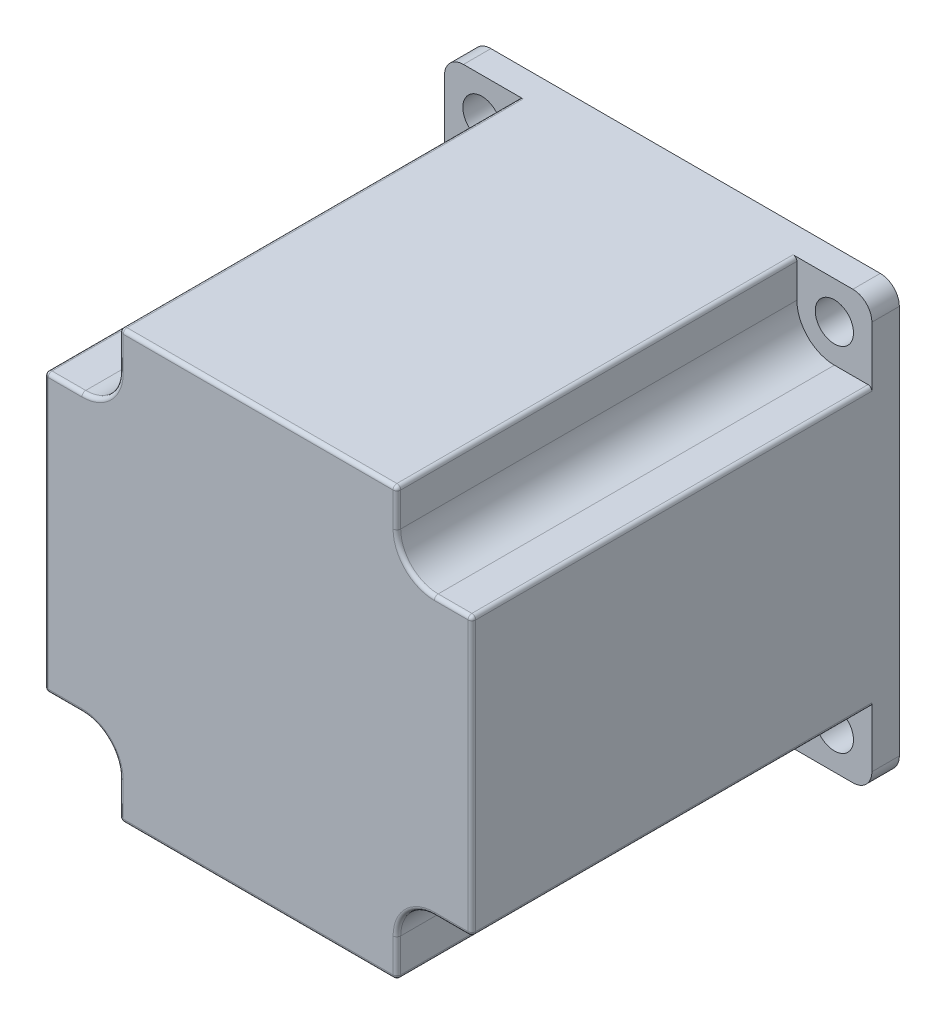
from build123d import *

# Parameters (mm, degrees)
SKETCH1_W           = 57
SKETCH1_H           = 57
BOSS_EXTRUDE1_DEPTH = 57
SKETCH2_R           = 2.55
CUT_EXTRUDE1_DEPTH  = 58
CUT_EXTRUDE2_DEPTH  = 53.34
SKETCH4_R           = 19.05
BOSS_EXTRUDE2_DEPTH = 1.6
SKETCH5_R           = 3.175
BOSS_EXTRUDE3_DEPTH = 19.4
CUT_EXTRUDE3_DEPTH  = 15
CHAMFER1_SIZE2      = 0.439940905
CHAMFER1_SIZE       = 0.254
FILLET1_R           = 2.54
FILLET2_R           = 0.508


with BuildPart() as part:
    # Sketch1 → Boss-Extrude1 (new body)
    with BuildSketch(Plane.XY):
        Rectangle(SKETCH1_W, SKETCH1_H)
    extrude(amount=BOSS_EXTRUDE1_DEPTH)

    # Sketch2 → Cut-Extrude1 (cut, through all)
    with BuildSketch(Plane.XY.offset(57)):
        with Locations((-23.5, 23.5)):
            Circle(SKETCH2_R)
        with Locations((23.5, 23.5)):
            Circle(SKETCH2_R)
        with Locations((23.5, -23.5)):
            Circle(SKETCH2_R)
        with Locations((-23.5, -23.5)):
            Circle(SKETCH2_R)
    extrude(amount=-CUT_EXTRUDE1_DEPTH, mode=Mode.SUBTRACT)

    # Sketch3 → Cut-Extrude2 (cut)
    with BuildSketch(Plane.XY.offset(57)):
        with BuildLine():
            Line((-18.5, 23.5), (-18.5, 28.5))
            Line((-18.5, 28.5), (-28.5, 28.5))
            Line((-28.5, 28.5), (-28.5, 18.5))
            Line((-28.5, 18.5), (-23.5, 18.5))
            ThreePointArc((-23.5, 18.5), (-19.964466094, 19.964466094), (-18.5, 23.5))
        make_face()
        with BuildLine():
            Line((28.5, 28.5), (28.5, 18.5))
            Line((28.5, 18.5), (23.5, 18.5))
            ThreePointArc((23.5, 18.5), (19.964466094, 19.964466094), (18.5, 23.5))
            Line((18.5, 23.5), (18.5, 28.5))
            Line((18.5, 28.5), (28.5, 28.5))
        make_face()
        with BuildLine():
            Line((-28.5, -28.5), (-28.5, -18.5))
            Line((-28.5, -18.5), (-23.5, -18.5))
            ThreePointArc((-23.5, -18.5), (-19.964466094, -19.964466094), (-18.5, -23.5))
            Line((-18.5, -23.5), (-18.5, -28.5))
            Line((-18.5, -28.5), (-28.5, -28.5))
        make_face()
        with BuildLine():
            Line((18.5, -23.5), (18.5, -28.5))
            Line((18.5, -28.5), (28.5, -28.5))
            Line((28.5, -28.5), (28.5, -18.5))
            Line((28.5, -18.5), (23.5, -18.5))
            ThreePointArc((23.5, -18.5), (19.964466094, -19.964466094), (18.5, -23.5))
        make_face()
    extrude(amount=-CUT_EXTRUDE2_DEPTH, mode=Mode.SUBTRACT)

    # Sketch4 → Boss-Extrude2 (add)
    with BuildSketch(Plane(origin=(0, 0, 0), x_dir=(-1, 0, 0), z_dir=(0, 0, -1))):
        Circle(SKETCH4_R)
    extrude(amount=BOSS_EXTRUDE2_DEPTH)

    # Sketch5 → Boss-Extrude3 (add)
    with BuildSketch(Plane(origin=(0, 0, -1.6), x_dir=(-1, 0, 0), z_dir=(0, 0, -1))):
        Circle(SKETCH5_R)
    extrude(amount=BOSS_EXTRUDE3_DEPTH)

    # Sketch7 → Cut-Extrude3 (cut)
    with BuildSketch(Plane(origin=(0, 0, -21), x_dir=(-1, 0, 0), z_dir=(0, 0, -1))):
        with BuildLine():
            Line((-1.234908904, 2.925), (-1.234908904, -2.925))
            ThreePointArc((-1.234908904, -2.925), (-3.175, 0), (-1.234908904, 2.925))
        make_face()
    extrude(amount=-CUT_EXTRUDE3_DEPTH, mode=Mode.SUBTRACT)

    # Chamfer1
    chamfer1_edges = [part.edges().sort_by_distance(p)[0] for p in [
        (-1.754962853, -2.645889337, -21),
    ]]
    chamfer(chamfer1_edges, length=CHAMFER1_SIZE, length2=CHAMFER1_SIZE2)

    # Fillet1
    fillet1_edges = [part.edges().sort_by_distance(p)[0] for p in [
        (-28.5, 28.5, 1.83),
        (28.5, -28.5, 1.83),
        (-28.5, -28.5, 1.83),
        (28.5, 28.5, 1.83),
    ]]
    fillet(fillet1_edges, radius=FILLET1_R)

    # Fillet2
    fillet2_edges = [part.edges().sort_by_distance(p)[0] for p in [
        (-28.5, 0, 57),
        (-19.964466094, 19.964466094, 57),
        (-18.5, 26, 57),
        (-26, 18.5, 57),
        (-28.5, 18.5, 30.33),
        (-18.5, 28.5, 30.33),
        (0, -28.5, 57),
        (28.5, 0, 57),
        (0, 28.5, 57),
        (19.964466094, 19.964466094, 57),
        (26, 18.5, 57),
        (18.5, 26, 57),
        (18.5, 28.5, 30.33),
        (28.5, 18.5, 30.33),
        (-19.964466094, -19.964466094, 57),
        (-26, -18.5, 57),
        (-18.5, -26, 57),
        (-18.5, -28.5, 30.33),
        (-28.5, -18.5, 30.33),
        (19.964466094, -19.964466094, 57),
        (18.5, -26, 57),
        (26, -18.5, 57),
        (28.5, -18.5, 30.33),
        (18.5, -28.5, 30.33),
    ]]
    fillet(fillet2_edges, radius=FILLET2_R)


solid = part.part
